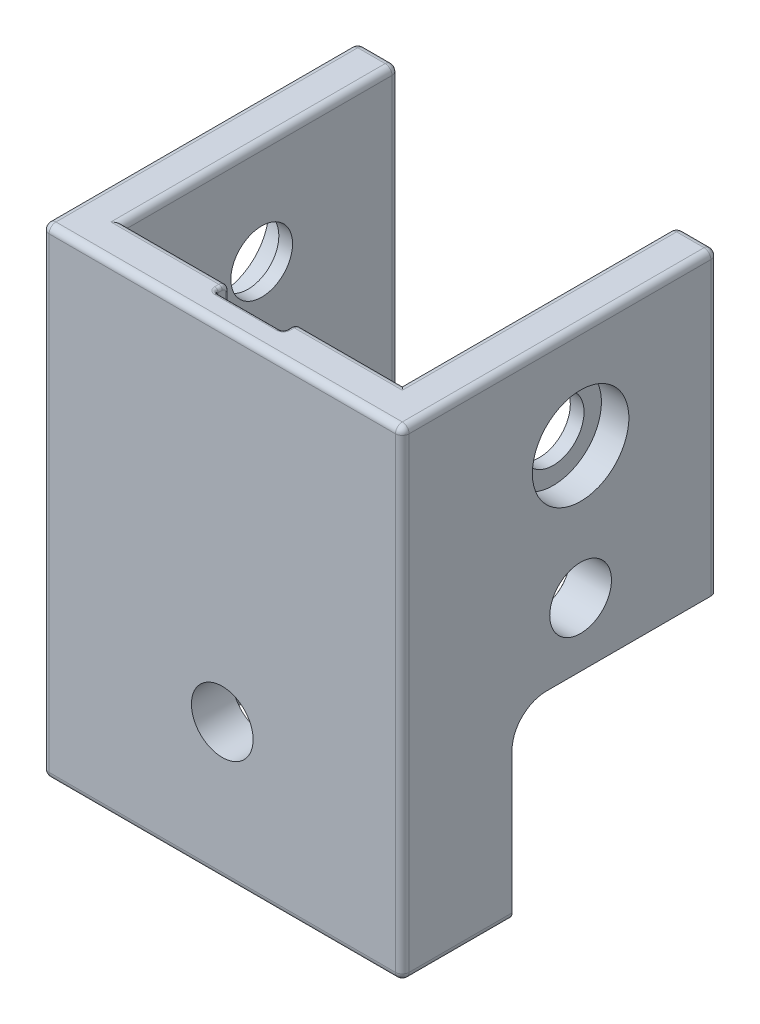
from build123d import *

# Parameters (mm, degrees)
BOSS_EXTRUDE1_DEPTH           = 70
SKETCH8_R                     = 4.5
CUT_EXTRUDE4_DEPTH            = 53.5
SKETCH10_R                    = 7.035
CUT_EXTRUDE5_DEPTH            = 4
FILLET13_R                    = 1
M8_CLEARANCE_HOLE1_AT_2_COUNT = 2
M8_CLEARANCE_HOLE1_AT_2_PITCH = 24.109474775
CUT_EXTRUDE6_REACH            = 54.5
SKETCH21_W                    = 30
SKETCH21_H                    = 26.5
M8_CLEARANCE_HOLE2_D          = 9
FILLET14_R                    = 5
SKETCH24_W                    = 10
SKETCH24_H                    = 38
CUT_EXTRUDE7_DEPTH            = 2.1
FILLET15_R                    = 0.5


with BuildPart() as part:
    # Sketch1 → Boss-Extrude1 (new body)
    with BuildSketch(Plane(origin=(0, 0, 0), x_dir=(1, 0, 0), z_dir=(0, 1, 0))):
        Polygon((-26.25, -26.25), (26.25, -26.25), (26.25, 19.75), (20.25, 19.75), (20.25, -20.25), (-20.25, -20.25), (-20.25, 19.75), (-26.25, 19.75), align=None)
    extrude(amount=BOSS_EXTRUDE1_DEPTH)

    # Sketch8 → Cut-Extrude4 (cut, through all)
    with BuildSketch(Plane(origin=(26.25, 0, 0), x_dir=(0, 0, -1), z_dir=(1, 0, 0))):
        with Locations((-0.25, 55)):
            Circle(SKETCH8_R)
    extrude(amount=-CUT_EXTRUDE4_DEPTH, mode=Mode.SUBTRACT)

    # Sketch10 → Cut-Extrude5 (cut)
    with BuildSketch(Plane.ZY.offset(26.25)):
        with Locations((0.25, 55)):
            Circle(SKETCH10_R)
    cut_extrude5 = extrude(amount=-CUT_EXTRUDE5_DEPTH, mode=Mode.SUBTRACT)

    # Mirror1: Cut-Extrude5 across plane
    add(cut_extrude5.mirror(Plane(origin=(0, 0, 0), x_dir=(0, 0, 1), z_dir=(1, 0, 0))), mode=Mode.SUBTRACT)

    # Fillet13
    fillet13_edges = [part.edges().sort_by_distance(p)[0] for p in [
        (26.25, 0, 3.25),
        (0, 0, 26.25),
        (0, 70, 20.25),
        (-26.25, 0, 3.25),
        (-23.25, 0, -19.75),
        (-20.25, 0, 0.25),
        (0, 0, 20.25),
        (20.25, 0, 0.25),
        (-20.25, 70, 0.25),
        (20.25, 35, -19.75),
        (26.25, 35, -19.75),
        (26.25, 35, 26.25),
        (-26.25, 35, 26.25),
        (-26.25, 35, -19.75),
        (-20.25, 35, -19.75),
        (-23.25, 70, -19.75),
        (-26.25, 70, 3.25),
        (0, 70, 26.25),
        (26.25, 70, 3.25),
        (23.25, 70, -19.75),
        (20.25, 70, 0.25),
        (23.25, 0, -19.75),
    ]]
    fillet(fillet13_edges, radius=FILLET13_R)

    # Sketch18 → M8 Clearance Hole1 (revolve, cut)
    with BuildSketch(Plane(origin=(-20.25, 35.786178525, 0.25), x_dir=(0, 0, -1), z_dir=(0, 1, 0))):
        Polygon((0, 0), (0, 15.703872786), (4.5, 13), (4.5, 0.025), (4.525, 0), align=None)
    m8_clearance_hole1 = revolve(axis=Axis((-13.9, 35.786178525, 0.25), (-1, 0, 0)), mode=Mode.SUBTRACT)

    # M8 Clearance Hole1 at 2: M8 Clearance Hole1 ×2
    with Locations(*[(0, -i * M8_CLEARANCE_HOLE1_AT_2_PITCH, 0) for i in range(1, M8_CLEARANCE_HOLE1_AT_2_COUNT)]):
        add(m8_clearance_hole1, mode=Mode.SUBTRACT)

    # Mirror2: M8 Clearance Hole1 across plane
    add(m8_clearance_hole1.mirror(Plane(origin=(0, 0, 0), x_dir=(0, 0, 1), z_dir=(1, 0, 0))), mode=Mode.SUBTRACT)

    # Mirror2 copy 1 sketch → Mirror2 copy 1 (revolve, cut)
    with BuildSketch(Plane(origin=(20.25, 11.676703751, 0.25), x_dir=(0, 0, -1), z_dir=(0, 1, 0))):
        Polygon((0, 0), (0, -15.703872786), (4.5, -13), (4.5, -0.025), (4.525, 0), align=None)
    revolve(axis=Axis((13.9, 11.676703751, 0.25), (-1, 0, 0)), mode=Mode.SUBTRACT)

    # Sketch21 → Cut-Extrude6 (cut, up to next)
    with BuildSketch(Plane.ZY.offset(-26.25), mode=Mode.PRIVATE) as cut_extrude6_sk1:
        with Locations((-4.75, 13.25)):
            Rectangle(SKETCH21_W, SKETCH21_H)
    cut_extrude6_tool1 = extrude(cut_extrude6_sk1.sketch, amount=CUT_EXTRUDE6_REACH, mode=Mode.PRIVATE) & part.part
    add(cut_extrude6_tool1.solids().sort_by_distance((26.25, 13.25, -4.75))[0], mode=Mode.SUBTRACT)

    # M8 Clearance Hole2 (through all)
    with Locations(Plane.XY.offset(26.25)):
        with Locations((0, 20)):
            Hole(M8_CLEARANCE_HOLE2_D / 2)

    # Fillet14
    fillet14_edges = [part.edges().sort_by_distance(p)[0] for p in [
        (23.25, 26.5, 10.25),
    ]]
    fillet(fillet14_edges, radius=FILLET14_R)

    # Sketch24 → Cut-Extrude7 (cut)
    with BuildSketch(Plane(origin=(0, 0, 20.25), x_dir=(-1, 0, 0), z_dir=(0, 0, -1))):
        with Locations((0, 51)):
            Rectangle(SKETCH24_W, SKETCH24_H)
    extrude(amount=-CUT_EXTRUDE7_DEPTH, mode=Mode.SUBTRACT)

    # Fillet15
    fillet15_edges = [part.edges().sort_by_distance(p)[0] for p in [
        (5, 69.707106781, 20.542893219),
        (-5, 69.707106781, 20.542893219),
        (5, 70, 21.8),
        (0, 70, 22.35),
        (5, 50.5, 20.25),
        (0, 32, 20.25),
        (-5, 50.5, 20.25),
        (-5, 51, 22.35),
        (-5, 70, 21.8),
        (0, 32, 22.35),
        (-5, 32, 21.3),
        (5, 51, 22.35),
        (5, 32, 21.3),
    ]]
    fillet(fillet15_edges, radius=FILLET15_R)


solid = part.part
